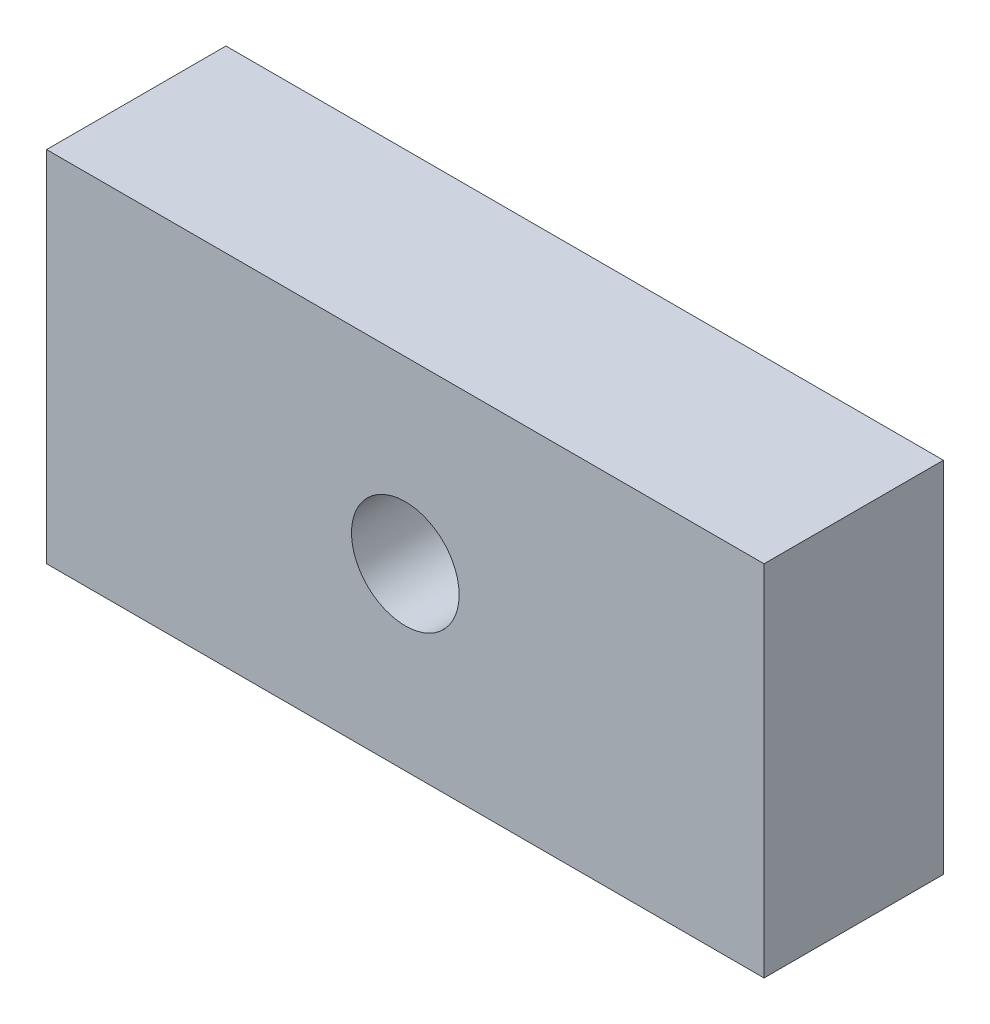
from build123d import *

# Parameters (mm, degrees)
SKICA1_W                 = 100
SKICA1_H                 = 50
P_IDAT_VYSUNUT_M1_DEPTH  = 25
ODEBRAT_VYSUNUT_M1_REACH = 27
SKICA2_R                 = 7.5


with BuildPart() as part:
    # Skica1 → Přidat vysunutím1 (new body)
    with BuildSketch(Plane.XY):
        Rectangle(SKICA1_W, SKICA1_H)
    extrude(amount=P_IDAT_VYSUNUT_M1_DEPTH)

    # Skica2 → Odebrat vysunutím1 (cut, up to next)
    with BuildSketch(Plane.XY.offset(25), mode=Mode.PRIVATE) as odebrat_vysunut_m1_sk1:
        Circle(SKICA2_R)
    odebrat_vysunut_m1_tool1 = extrude(odebrat_vysunut_m1_sk1.sketch, amount=-ODEBRAT_VYSUNUT_M1_REACH, mode=Mode.PRIVATE) & part.part
    add(odebrat_vysunut_m1_tool1.solids().sort_by_distance((0, 0, 25))[0], mode=Mode.SUBTRACT)


solid = part.part
